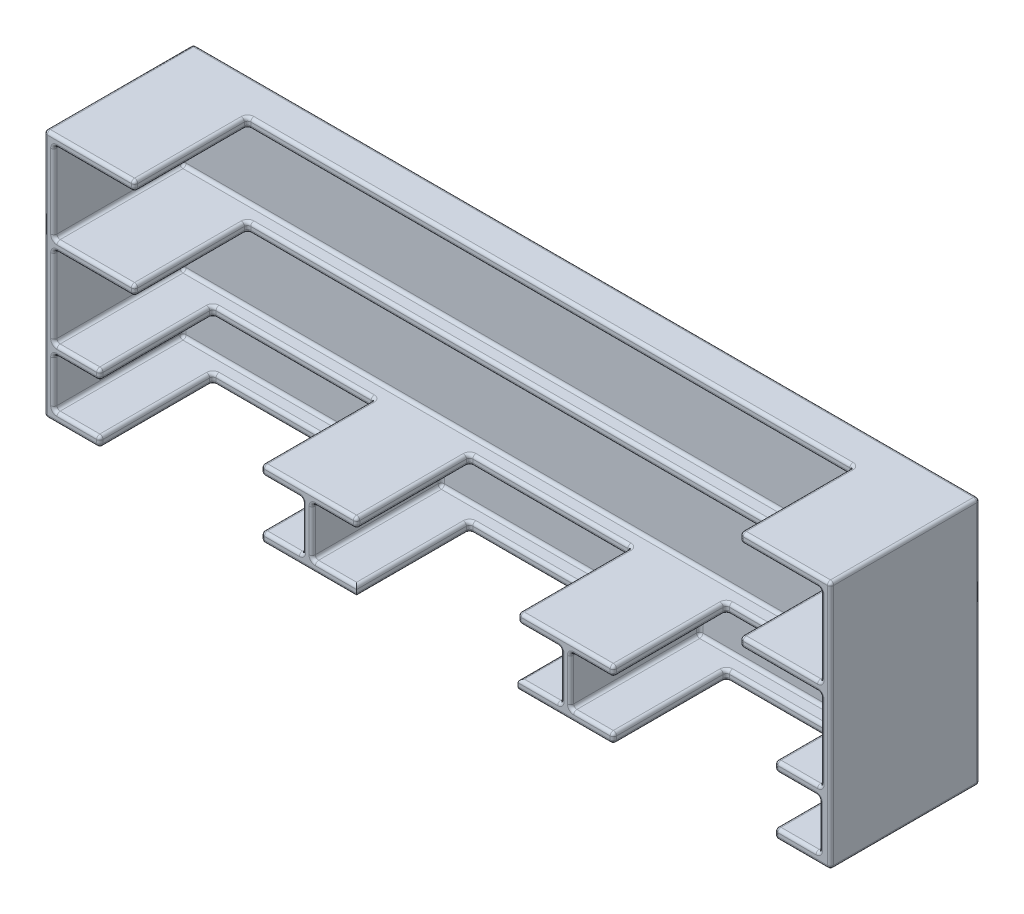
from build123d import *

# Parameters (mm, degrees)
SKETCH1_W           = 123.698
SKETCH1_H           = 39.116
SKETCH1_W_2         = 120.65
SKETCH1_H_2         = 12.7
SKETCH1_W_3         = 39.116
SKETCH1_H_3         = 7.62
BOSS_EXTRUDE1_DEPTH = 20.32
SKETCH3_W           = 95.25
SKETCH3_H           = 28.448
CUT_EXTRUDE1_DEPTH  = 17.78
SKETCH4_W           = 25.4
SKETCH4_H           = 38.1
CUT_EXTRUDE2_DEPTH  = 10.668
SKETCH2_W           = 123.698
SKETCH2_H           = 39.116
BOSS_EXTRUDE2_DEPTH = 3.175
FILLET1_R           = 0.5


with BuildPart() as part:
    # Sketch1 → Boss-Extrude1 (new body)
    with BuildSketch(Plane.XY):
        with Locations((-61.849, 19.558)):
            Rectangle(SKETCH1_W, SKETCH1_H)
        with Locations((-61.849, 31.242)):
            Rectangle(SKETCH1_W_2, SKETCH1_H_2, mode=Mode.SUBTRACT)
        with Locations((-61.849, 17.018)):
            Rectangle(SKETCH1_W_2, SKETCH1_H_2, mode=Mode.SUBTRACT)
        with Locations((-102.616, 5.334)):
            Rectangle(SKETCH1_W_3, SKETCH1_H_3, mode=Mode.SUBTRACT)
        with Locations((-61.976, 5.334)):
            Rectangle(SKETCH1_W_3, SKETCH1_H_3, mode=Mode.SUBTRACT)
        with Locations((-21.336, 5.334)):
            Rectangle(SKETCH1_W_3, SKETCH1_H_3, mode=Mode.SUBTRACT)
    extrude(amount=BOSS_EXTRUDE1_DEPTH)

    # Sketch3 → Cut-Extrude1 (cut)
    with BuildSketch(Plane.XY.offset(20.32)):
        with Locations((-61.849, 24.892)):
            Rectangle(SKETCH3_W, SKETCH3_H)
    extrude(amount=-CUT_EXTRUDE1_DEPTH, mode=Mode.SUBTRACT)

    # Sketch4 → Cut-Extrude2 (cut)
    with BuildSketch(Plane(origin=(0, 0, 0), x_dir=(-1, 0, 0), z_dir=(0, -1, 0))):
        with Locations((102.235, -21.59)):
            Rectangle(SKETCH4_W, SKETCH4_H)
        with Locations((61.849, -21.59)):
            Rectangle(SKETCH4_W, SKETCH4_H)
        with Locations((21.463, -21.59)):
            Rectangle(SKETCH4_W, SKETCH4_H)
    extrude(amount=-CUT_EXTRUDE2_DEPTH, mode=Mode.SUBTRACT)

    # Sketch2 → Boss-Extrude2 (add)
    with BuildSketch(Plane(origin=(0, 0, 0), x_dir=(-1, 0, 0), z_dir=(0, 0, -1))):
        with Locations((61.849, 19.558)):
            Rectangle(SKETCH2_W, SKETCH2_H)
    extrude(amount=BOSS_EXTRUDE2_DEPTH)

    # Fillet1
    fillet1_edges = [part.edges().sort_by_distance(p)[0] for p in [
        (-123.698, 0, 8.5725),
        (-61.849, 0, -3.175),
        (0, 0, 8.5725),
        (-4.3815, 0, 20.32),
        (-8.763, 0, 11.43),
        (-21.463, 0, 2.54),
        (-34.163, 0, 11.43),
        (-41.656, 0, 20.32),
        (-49.149, 0, 11.43),
        (-61.849, 0, 2.54),
        (-74.549, 0, 11.43),
        (-82.042, 0, 20.32),
        (-89.535, 0, 11.43),
        (-102.235, 0, 2.54),
        (-114.935, 0, 11.43),
        (-119.3165, 0, 20.32),
        (-114.935, 0.762, 20.32),
        (-118.5545, 1.524, 20.32),
        (-122.174, 5.334, 20.32),
        (-118.5545, 9.144, 20.32),
        (-114.935, 9.906, 20.32),
        (-118.5545, 10.668, 20.32),
        (-122.174, 17.018, 20.32),
        (-115.824, 23.368, 20.32),
        (-109.474, 24.13, 20.32),
        (-115.824, 24.892, 20.32),
        (-122.174, 31.242, 20.32),
        (-115.824, 37.592, 20.32),
        (-109.474, 38.354, 20.32),
        (-116.586, 39.116, 20.32),
        (-123.698, 19.558, 20.32),
        (0, 39.116, 8.5725),
        (-61.849, 39.116, -3.175),
        (-123.698, 39.116, 8.5725),
        (-109.474, 39.116, 11.43),
        (-61.849, 39.116, 2.54),
        (-14.224, 39.116, 11.43),
        (-7.112, 39.116, 20.32),
        (-14.224, 38.354, 20.32),
        (-14.224, 38.354, 2.54),
        (-14.224, 37.592, 11.43),
        (-61.849, 37.592, 2.54),
        (-109.474, 38.354, 2.54),
        (-109.474, 37.592, 11.43),
        (-61.849, 37.592, 0),
        (-1.524, 37.592, 10.16),
        (-7.874, 37.592, 20.32),
        (-122.174, 37.592, 10.16),
        (-1.524, 24.892, 10.16),
        (-1.524, 31.242, 0),
        (-1.524, 31.242, 20.32),
        (-61.849, 24.892, 0),
        (-122.174, 31.242, 0),
        (-122.174, 24.892, 10.16),
        (-109.474, 24.892, 11.43),
        (-61.849, 24.892, 2.54),
        (-14.224, 24.892, 11.43),
        (-7.874, 24.892, 20.32),
        (-14.224, 24.13, 20.32),
        (-14.224, 24.13, 2.54),
        (-14.224, 23.368, 11.43),
        (-61.849, 23.368, 2.54),
        (-109.474, 24.13, 2.54),
        (-109.474, 23.368, 11.43),
        (-61.849, 23.368, 0),
        (-1.524, 23.368, 10.16),
        (-7.874, 23.368, 20.32),
        (-122.174, 23.368, 10.16),
        (-1.524, 10.668, 10.16),
        (-1.524, 17.018, 0),
        (-1.524, 17.018, 20.32),
        (-61.849, 10.668, 0),
        (-122.174, 17.018, 0),
        (-122.174, 10.668, 10.16),
        (-114.935, 10.668, 11.43),
        (-102.235, 10.668, 2.54),
        (-89.535, 10.668, 11.43),
        (-82.042, 10.668, 20.32),
        (-74.549, 10.668, 11.43),
        (-61.849, 10.668, 2.54),
        (-49.149, 10.668, 11.43),
        (-41.656, 10.668, 20.32),
        (-34.163, 10.668, 11.43),
        (-21.463, 10.668, 2.54),
        (-8.763, 10.668, 11.43),
        (-5.1435, 10.668, 20.32),
        (-8.763, 9.144, 11.43),
        (-8.763, 9.906, 20.32),
        (-8.763, 9.906, 2.54),
        (-21.336, 9.144, 0),
        (-1.778, 9.144, 10.16),
        (-5.2705, 9.144, 20.32),
        (-21.463, 9.144, 2.54),
        (-34.163, 9.144, 11.43),
        (-37.5285, 9.144, 20.32),
        (-40.894, 9.144, 10.16),
        (-40.894, 1.524, 10.16),
        (-40.894, 5.334, 0),
        (-40.894, 5.334, 20.32),
        (-21.336, 1.524, 0),
        (-37.5285, 1.524, 20.32),
        (-34.163, 1.524, 11.43),
        (-21.463, 1.524, 2.54),
        (-8.763, 1.524, 11.43),
        (-5.2705, 1.524, 20.32),
        (-1.778, 1.524, 10.16),
        (-1.778, 5.334, 0),
        (-1.778, 5.334, 20.32),
        (-34.163, 9.906, 2.54),
        (-34.163, 9.906, 20.32),
        (-49.149, 9.144, 11.43),
        (-49.149, 9.906, 20.32),
        (-49.149, 9.906, 2.54),
        (-61.976, 9.144, 0),
        (-42.418, 9.144, 10.16),
        (-45.7835, 9.144, 20.32),
        (-61.849, 9.144, 2.54),
        (-74.549, 9.144, 11.43),
        (-78.0415, 9.144, 20.32),
        (-81.534, 9.144, 10.16),
        (-81.534, 1.524, 10.16),
        (-81.534, 5.334, 0),
        (-81.534, 5.334, 20.32),
        (-61.976, 1.524, 0),
        (-78.0415, 1.524, 20.32),
        (-74.549, 1.524, 11.43),
        (-61.849, 1.524, 2.54),
        (-49.149, 1.524, 11.43),
        (-45.7835, 1.524, 20.32),
        (-42.418, 1.524, 10.16),
        (-42.418, 5.334, 0),
        (-42.418, 5.334, 20.32),
        (-74.549, 9.906, 2.54),
        (-74.549, 9.906, 20.32),
        (-89.535, 9.144, 11.43),
        (-89.535, 9.906, 20.32),
        (-89.535, 9.906, 2.54),
        (-102.235, 9.144, 2.54),
        (-114.935, 9.906, 2.54),
        (-114.935, 9.144, 11.43),
        (-102.616, 9.144, 0),
        (-83.058, 9.144, 10.16),
        (-86.2965, 9.144, 20.32),
        (-122.174, 9.144, 10.16),
        (-83.058, 1.524, 10.16),
        (-83.058, 5.334, 0),
        (-83.058, 5.334, 20.32),
        (-102.616, 1.524, 0),
        (-122.174, 5.334, 0),
        (-122.174, 1.524, 10.16),
        (-114.935, 1.524, 11.43),
        (-102.235, 1.524, 2.54),
        (-89.535, 1.524, 11.43),
        (-86.2965, 1.524, 20.32),
        (-114.935, 0.762, 2.54),
        (-89.535, 0.762, 2.54),
        (-89.535, 0.762, 20.32),
        (-74.549, 0.762, 2.54),
        (-49.149, 0.762, 2.54),
        (-34.163, 0.762, 20.32),
        (-34.163, 0.762, 2.54),
        (-8.763, 0.762, 2.54),
        (-8.763, 0.762, 20.32),
        (0, 19.558, 20.32),
        (0, 19.558, -3.175),
        (-123.698, 19.558, -3.175),
    ]]
    fillet(fillet1_edges, radius=FILLET1_R)


solid = part.part
